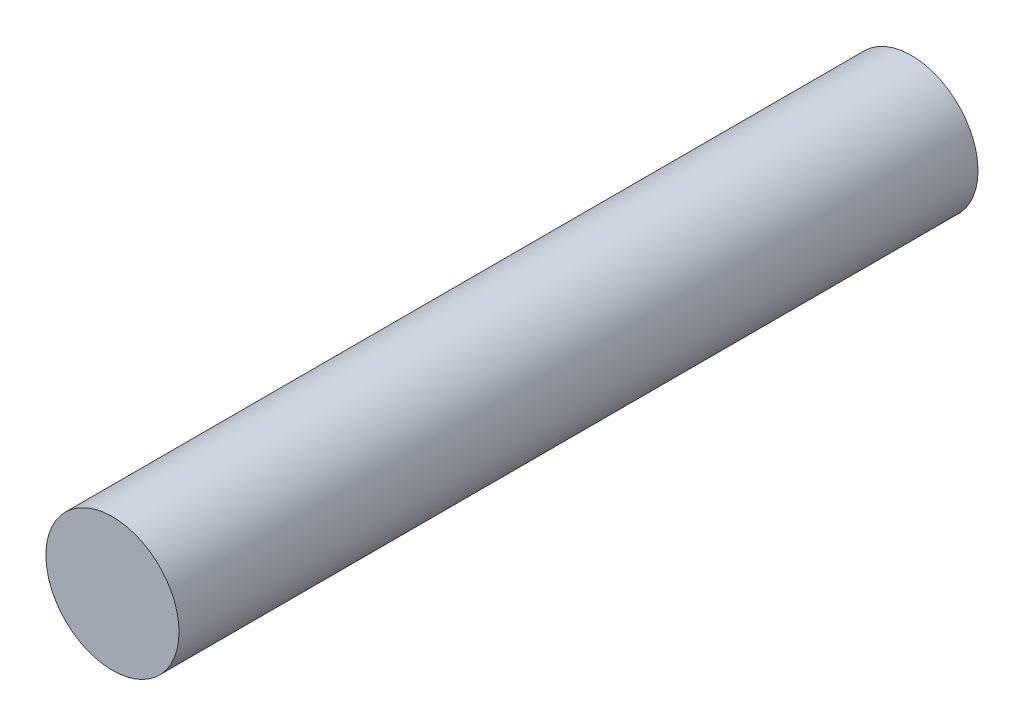
from build123d import *

# Parameters (mm, degrees)
SKETCH1_R           = 1
BOSS_EXTRUDE1_DEPTH = 12


with BuildPart() as part:
    # Sketch1 → Boss-Extrude1 (new body)
    with BuildSketch(Plane.XY):
        Circle(SKETCH1_R)
    extrude(amount=BOSS_EXTRUDE1_DEPTH)


solid = part.part
